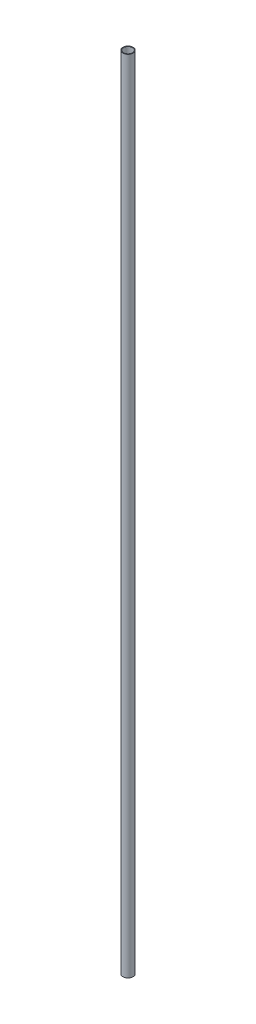
from build123d import *

# Parameters (mm, degrees)
SKETCH1_R           = 20
SKETCH1_R_2         = 17.46
BOSS_EXTRUDE1_DEPTH = 3131.82


with BuildPart() as part:
    # Sketch1 → Boss-Extrude1 (new body)
    with BuildSketch(Plane(origin=(0, 0, 0), x_dir=(1, 0, 0), z_dir=(0, 1, 0))):
        Circle(SKETCH1_R)
        Circle(SKETCH1_R_2, mode=Mode.SUBTRACT)
    extrude(amount=BOSS_EXTRUDE1_DEPTH)


solid = part.part
